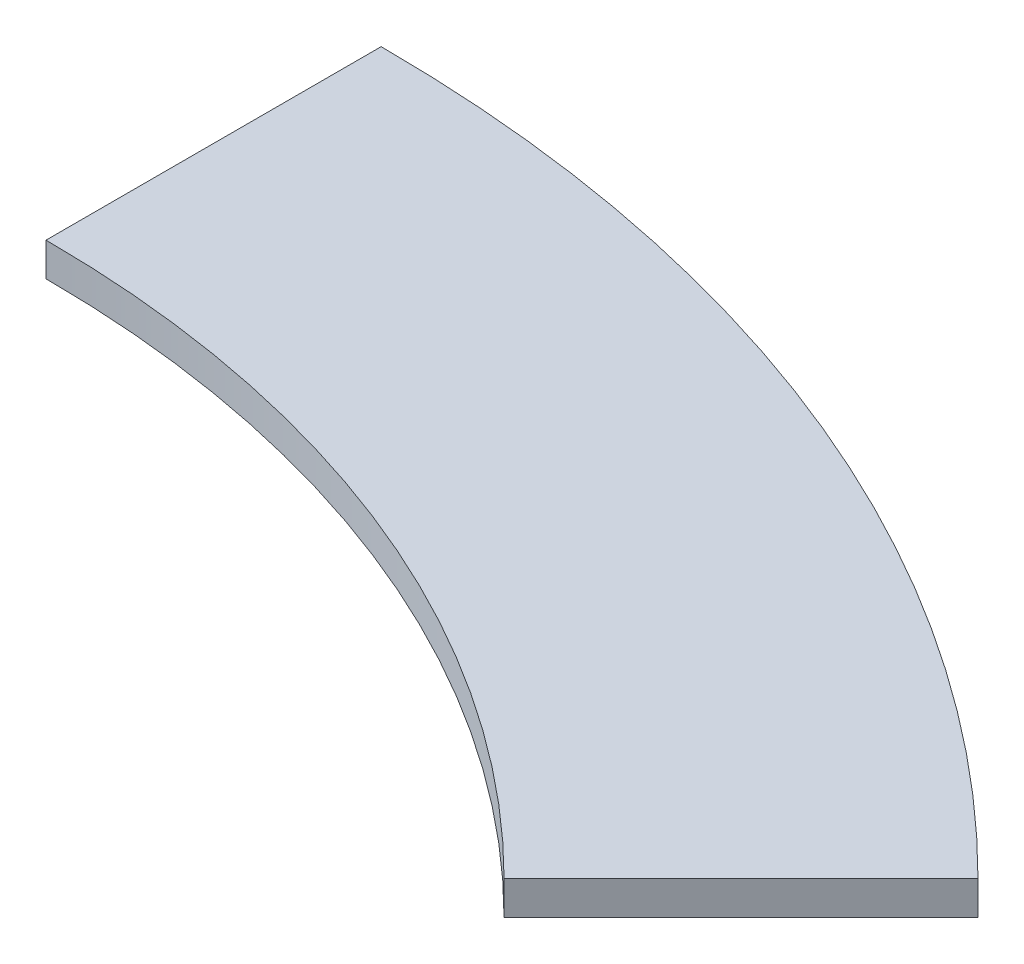
from build123d import *

# Parameters (mm, degrees)
BOSS_EXTRUDE1_DEPTH = 10


with BuildPart() as part:
    # Sketch1 → Boss-Extrude1 (new body)
    with BuildSketch(Plane(origin=(0, 0, 0), x_dir=(1, 0, 0), z_dir=(0, 1, 0))):
        with BuildLine():
            ThreePointArc((0, 430), (164.553875917, 397.26819898), (304.05591591, 304.05591591))
            Line((304.05591591, 304.05591591), (233.345237792, 233.345237792))
            ThreePointArc((233.345237792, 233.345237792), (126.28553268, 304.880245729), (0, 330))
            Line((0, 330), (0, 430))
        make_face()
    extrude(amount=BOSS_EXTRUDE1_DEPTH)


solid = part.part
